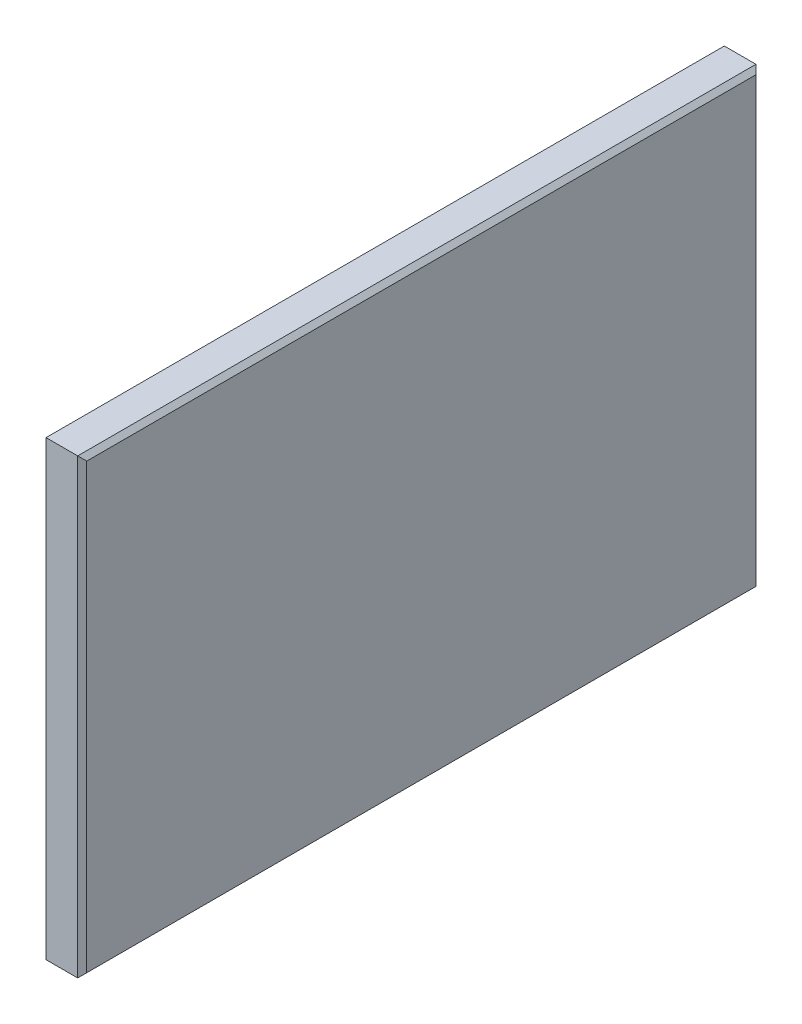
from build123d import *

# Parameters (mm, degrees)
SKETCH1_W           = 76.2
SKETCH1_H           = 50.8
BOSS_EXTRUDE1_DEPTH = 4.572
CHAMFER1_SIZE       = 0.508


with BuildPart() as part:
    # Sketch1 → Boss-Extrude1 (new body)
    with BuildSketch(Plane(origin=(0, 0, 0), x_dir=(0, 0, -1), z_dir=(1, 0, 0))):
        Rectangle(SKETCH1_W, SKETCH1_H)
    extrude(amount=BOSS_EXTRUDE1_DEPTH)

    # Chamfer1
    chamfer1_edges = [part.edges().sort_by_distance(p)[0] for p in [
        (4.572, -25.4, 0),
        (4.572, 0, -38.1),
        (4.572, 0, 38.1),
        (4.572, 25.4, 0),
        (0, -25.4, 0),
        (0, 0, -38.1),
        (0, 0, 38.1),
        (0, 25.4, 0),
    ]]
    chamfer(chamfer1_edges, length=CHAMFER1_SIZE)


solid = part.part
